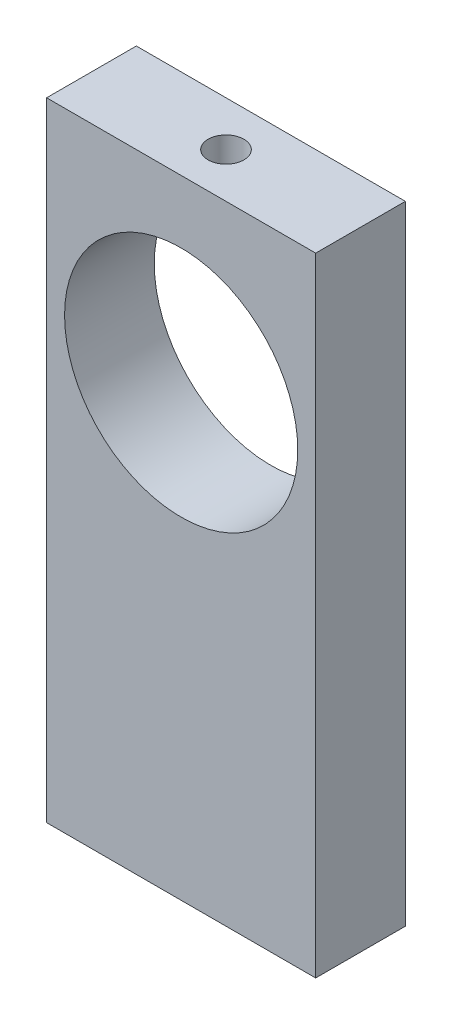
from build123d import *

# Parameters (mm, degrees)
SKETCH1_W           = 15
SKETCH1_H           = 35
BOSS_EXTRUDE1_DEPTH = 5
SKETCH2_R           = 6.5
CUT_EXTRUDE1_DEPTH  = 5
CUT_EXTRUDE2_REACH  = 37
SKETCH3_R           = 1


with BuildPart() as part:
    # Sketch1 → Boss-Extrude1 (new body)
    with BuildSketch(Plane.XY):
        with Locations((4.397758993, 4.909943839)):
            Rectangle(SKETCH1_W, SKETCH1_H)
    extrude(amount=BOSS_EXTRUDE1_DEPTH)

    # Sketch2 → Cut-Extrude1 (cut)
    with BuildSketch(Plane(origin=(0, 0, 0), x_dir=(-1, 0, 0), z_dir=(0, 0, -1))):
        with Locations((-4.397758993, 12.409943839)):
            Circle(SKETCH2_R)
    extrude(amount=-CUT_EXTRUDE1_DEPTH, mode=Mode.SUBTRACT)

    # Sketch3 → Cut-Extrude2 (cut, up to next)
    with BuildSketch(Plane(origin=(0, 22.409943839, 0), x_dir=(1, 0, 0), z_dir=(0, 1, 0)), mode=Mode.PRIVATE) as cut_extrude2_sk1:
        with Locations((4.397758993, -2.5)):
            Circle(SKETCH3_R)
    cut_extrude2_tool1 = extrude(cut_extrude2_sk1.sketch, amount=-CUT_EXTRUDE2_REACH, mode=Mode.PRIVATE) & part.part
    add(cut_extrude2_tool1.solids().sort_by_distance((4.397759, 22.409944, 2.5))[0], mode=Mode.SUBTRACT)


solid = part.part
